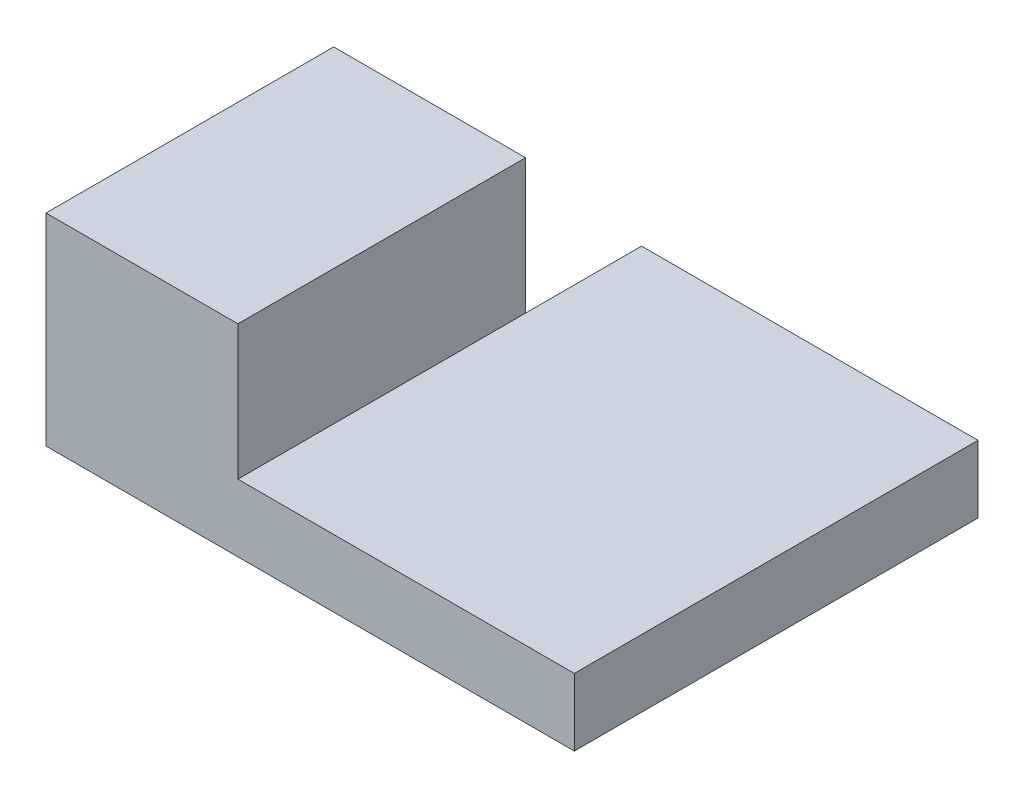
from build123d import *

# Parameters (mm, degrees)
BOSS_EXTRUDE1_DEPTH = 10
SKETCH1_3_W         = 28.522065562
SKETCH1_3_H         = 42.754608123
BOSS_EXTRUDE2_DEPTH = 30


with BuildPart() as part:
    # Sketch1 → Boss-Extrude1 (new body)
    with BuildSketch(Plane(origin=(0, 0, 0), x_dir=(1, 0, 0), z_dir=(0, 1, 0))):
        Polygon((25, 30), (-25, 30), (-25, 12.754608123), (-25, -30), (25, -30), align=None)
    extrude(amount=BOSS_EXTRUDE1_DEPTH)

    # Sketch1_3 → Boss-Extrude2 (add)
    with BuildSketch(Plane(origin=(0, 0, 0), x_dir=(1, 0, 0), z_dir=(0, 1, 0))):
        with Locations((-39.261032781, -8.622695939)):
            Rectangle(SKETCH1_3_W, SKETCH1_3_H)
    extrude(amount=BOSS_EXTRUDE2_DEPTH)


solid = part.part
